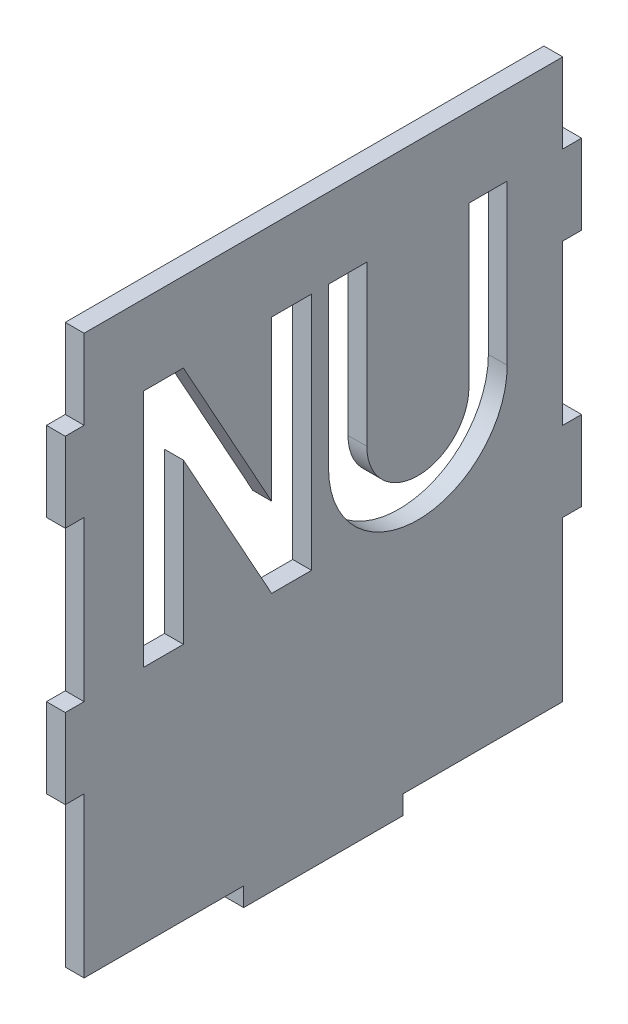
from build123d import *

# Parameters (mm, degrees)
BOSS_EXTRUDE1_DEPTH = 3


with BuildPart() as part:
    # Sketch1 → Boss-Extrude1 (new body)
    with BuildSketch(Plane(origin=(0, 0, 0), x_dir=(0, 0, -1), z_dir=(1, 0, 0))):
        Polygon((-38.1, -17.2847), (-38.1, -20.8153), (-38.1, -31.75), (-12.7, -31.75), (-12.7, -34.75), (12.7, -34.75), (12.7, -31.75), (38.1, -31.75), (38.1, -20.8153), (38.1, -17.2847), (38.1, -6.35), (41.1, -6.35), (41.1, 6.35), (38.1, 6.35), (38.1, 31.75), (41.1, 31.75), (41.1, 44.45), (38.1, 44.45), (38.1, 57.15), (-38.1, 57.15), (-38.1, 44.45), (-41.1, 44.45), (-41.1, 31.75), (-38.1, 31.75), (-38.1, 6.35), (-41.1, 6.35), (-41.1, -6.35), (-38.1, -6.35), align=None)
        Polygon((-22.288981843, 44.45), (-8.242290985, 19.05), (-8.242290985, 44.45), (-1.892290985, 44.45), (-1.892290985, 6.35), (-8.242290985, 6.35), (-22.288981843, 31.75), (-22.288981843, 6.35), (-28.638981843, 6.35), (-28.638981843, 44.45), align=None, mode=Mode.SUBTRACT)
        with BuildLine():
            Line((23.165757053, 44.45), (29.261757053, 44.45))
            Line((29.261757053, 44.45), (29.261757053, 19.05))
            ThreePointArc((29.261757053, 19.05), (15.037757053, 4.826), (0.813757053, 19.05))
            Line((0.813757053, 19.05), (0.813757053, 44.45))
            Line((0.813757053, 44.45), (6.909757053, 44.45))
            Line((6.909757053, 44.45), (6.909757053, 19.05))
            ThreePointArc((6.909757053, 19.05), (15.037757053, 10.922), (23.165757053, 19.05))
            Line((23.165757053, 19.05), (23.165757053, 44.45))
        make_face(mode=Mode.SUBTRACT)
    extrude(amount=BOSS_EXTRUDE1_DEPTH)


solid = part.part
